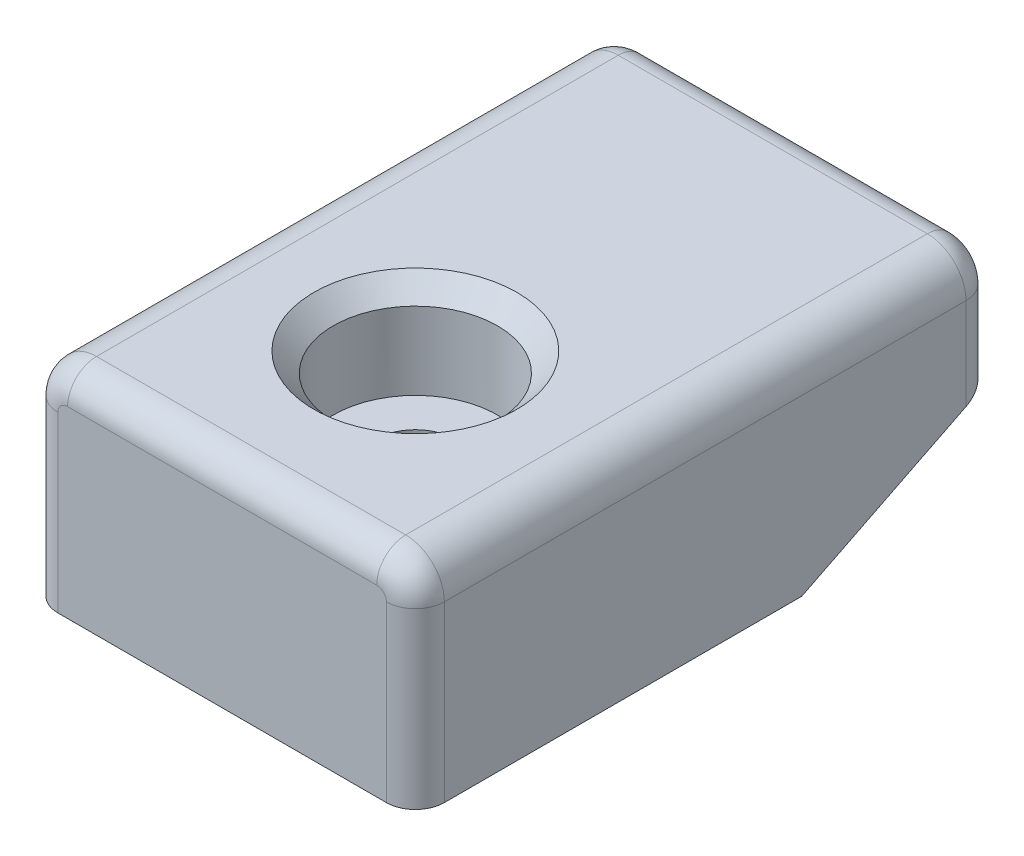
from build123d import *

# Parameters (mm, degrees)
SKETCH1_W           = 40
SKETCH1_H           = 60
SKETCH1_R           = 4.15
BOSS_EXTRUDE1_DEPTH = 11
SKETCH2_R           = 8.5
CUT_EXTRUDE1_DEPTH  = 10
FILLET1_R           = 4
CHAMFER1_SIZE       = 2
CHAMFER2_SIZE       = 20
CHAMFER2_SIZE2      = 10
FILLET2_R           = 3


with BuildPart() as part:
    # Sketch1 → Boss-Extrude1 (new body, symmetric)
    with BuildSketch(Plane(origin=(0, 0, 0), x_dir=(1, 0, 0), z_dir=(0, 1, 0))):
        with Locations((0, 0.089127558)):
            Rectangle(SKETCH1_W, SKETCH1_H)
        with Locations((0, -9.910872442)):
            Circle(SKETCH1_R, mode=Mode.SUBTRACT)
    extrude(amount=BOSS_EXTRUDE1_DEPTH, both=True)

    # Sketch2 → Cut-Extrude1 (cut)
    with BuildSketch(Plane(origin=(0, 11, 0), x_dir=(1, 0, 0), z_dir=(0, 1, 0))):
        with Locations((0, -9.910872442)):
            Circle(SKETCH2_R)
    extrude(amount=-CUT_EXTRUDE1_DEPTH, mode=Mode.SUBTRACT)

    # Fillet1
    fillet1_edges = [part.edges().sort_by_distance(p)[0] for p in [
        (-20, 11, -0.089127558),
        (20, 11, -0.089127558),
    ]]
    fillet(fillet1_edges, radius=FILLET1_R)

    # Chamfer1
    chamfer1_edges = [part.edges().sort_by_distance(p)[0] for p in [
        (-8.5, 11, 9.910872442),
    ]]
    chamfer(chamfer1_edges, length=CHAMFER1_SIZE)

    # Chamfer2
    chamfer2_edges = [part.edges().sort_by_distance(p)[0] for p in [
        (0, -11, -30.089127558),
    ]]
    chamfer2_side = [part.faces().sort_by_distance(p)[0] for p in [
        (0, -11, -0.319769187),
    ]]
    chamfer(chamfer2_edges, length=CHAMFER2_SIZE, length2=CHAMFER2_SIZE2, reference=chamfer2_side[0])

    # Fillet2
    fillet2_edges = [part.edges().sort_by_distance(p)[0] for p in [
        (0, 11, -30.089127558),
        (0, 11, 29.910872442),
        (20, -2, 29.910872442),
        (-20, -2, 29.910872442),
        (18.828427125, 9.828427125, 29.910872442),
        (-18.828427125, 9.828427125, 29.910872442),
        (-20, 3, -30.089127558),
        (20, 3, -30.089127558),
        (18.828427125, 9.828427125, -30.089127558),
        (-18.828427125, 9.828427125, -30.089127558),
    ]]
    fillet(fillet2_edges, radius=FILLET2_R)


solid = part.part
